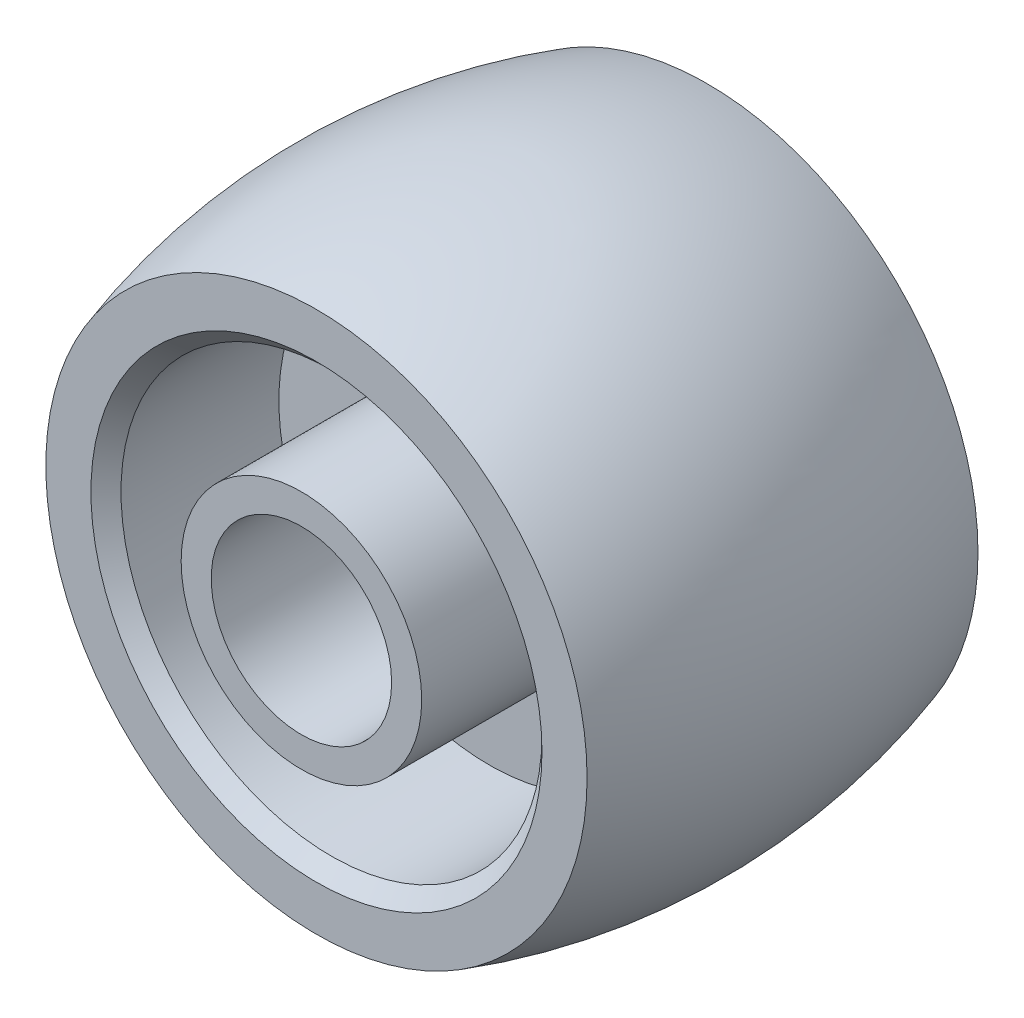
from build123d import *


with BuildPart() as part:
    # Esquisse1 → Révolution1 (revolve)
    with BuildSketch(Plane(origin=(0, 0, 0), x_dir=(0, 0, -1), z_dir=(1, 0, 0))):
        with BuildLine():
            Line((7, 3), (-7, 3))
            Line((-7, 3), (-7, 4))
            Line((-7, 4), (-0.75, 4))
            Line((-0.75, 4), (-0.75, 7))
            Line((-0.75, 7), (-6, 7))
            Line((-6, 7), (-6.5, 7.5))
            Line((-6.5, 7.5), (-6.5, 9))
            ThreePointArc((-6.5, 9), (0, 10), (6.5, 9))
            Line((6.5, 9), (6.5, 7.5))
            Line((6.5, 7.5), (6, 7))
            Line((6, 7), (0.75, 7))
            Line((0.75, 7), (0.75, 4))
            Line((0.75, 4), (7, 4))
            Line((7, 4), (7, 3))
        make_face()
    revolve(axis=Axis((0, 0, 4.7147115), (0, 0, -1)))


solid = part.part
